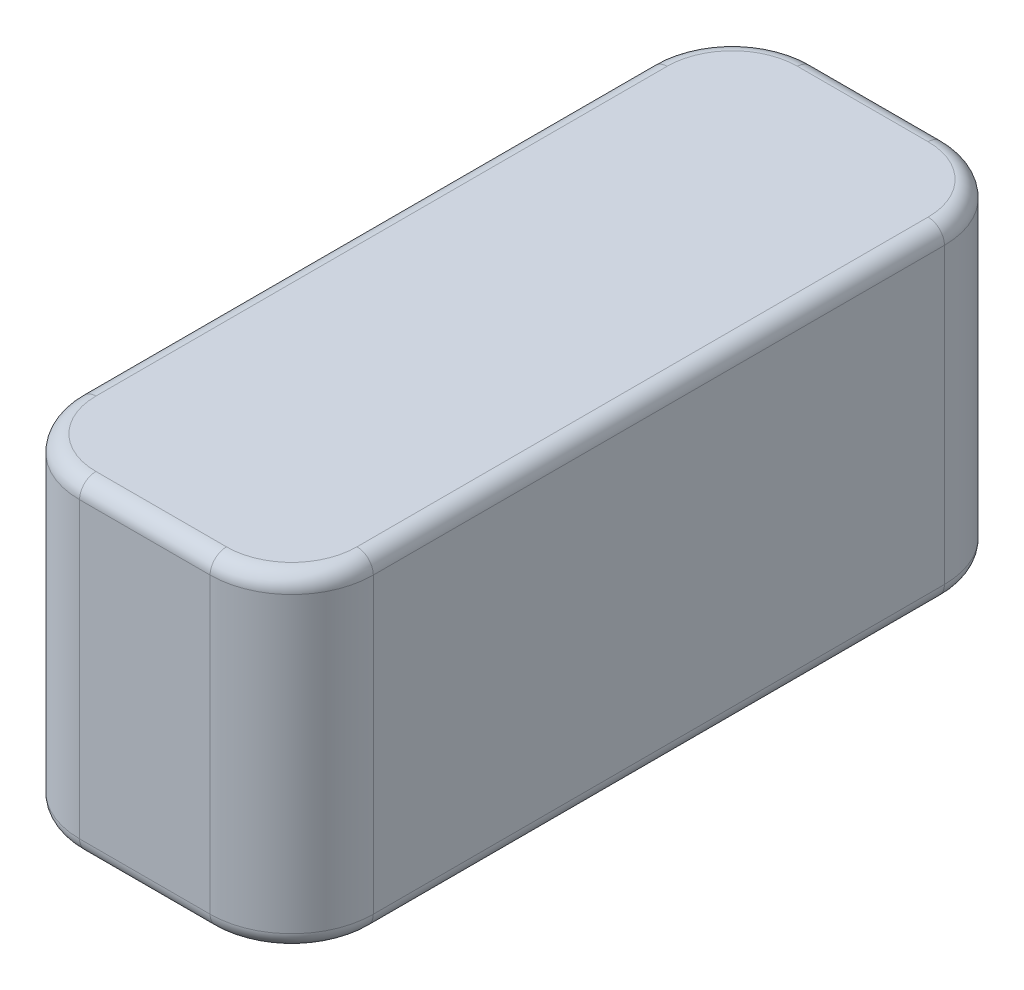
from build123d import *

# Parameters (mm, degrees)
SKETCH1_W           = 18
SKETCH1_H           = 45
BOSS_EXTRUDE1_DEPTH = 20
FILLET1_R           = 5
FILLET2_R           = 1


with BuildPart() as part:
    # Sketch1 → Boss-Extrude1 (new body)
    with BuildSketch(Plane(origin=(0, 0, 0), x_dir=(1, 0, 0), z_dir=(0, 1, 0))):
        Rectangle(SKETCH1_W, SKETCH1_H)
    extrude(amount=BOSS_EXTRUDE1_DEPTH)

    # Fillet1
    fillet1_edges = [part.edges().sort_by_distance(p)[0] for p in [
        (-9, 10, -22.5),
        (9, 10, -22.5),
        (9, 10, 22.5),
        (-9, 10, 22.5),
    ]]
    fillet(fillet1_edges, radius=FILLET1_R)

    # Fillet2
    fillet2_edges = [part.edges().sort_by_distance(p)[0] for p in [
        (9, 0, 0),
        (9, 20, 0),
        (-9, 0, 0),
        (0, 0, -22.5),
        (0, 0, 22.5),
        (-7.535533906, 0, -21.035533906),
        (7.535533906, 0, -21.035533906),
        (-7.535533906, 0, 21.035533906),
        (7.535533906, 0, 21.035533906),
        (0, 20, 22.5),
        (-9, 20, 0),
        (0, 20, -22.5),
        (-7.535533906, 20, -21.035533906),
        (7.535533906, 20, -21.035533906),
        (-7.535533906, 20, 21.035533906),
        (7.535533906, 20, 21.035533906),
    ]]
    fillet(fillet2_edges, radius=FILLET2_R)


solid = part.part
